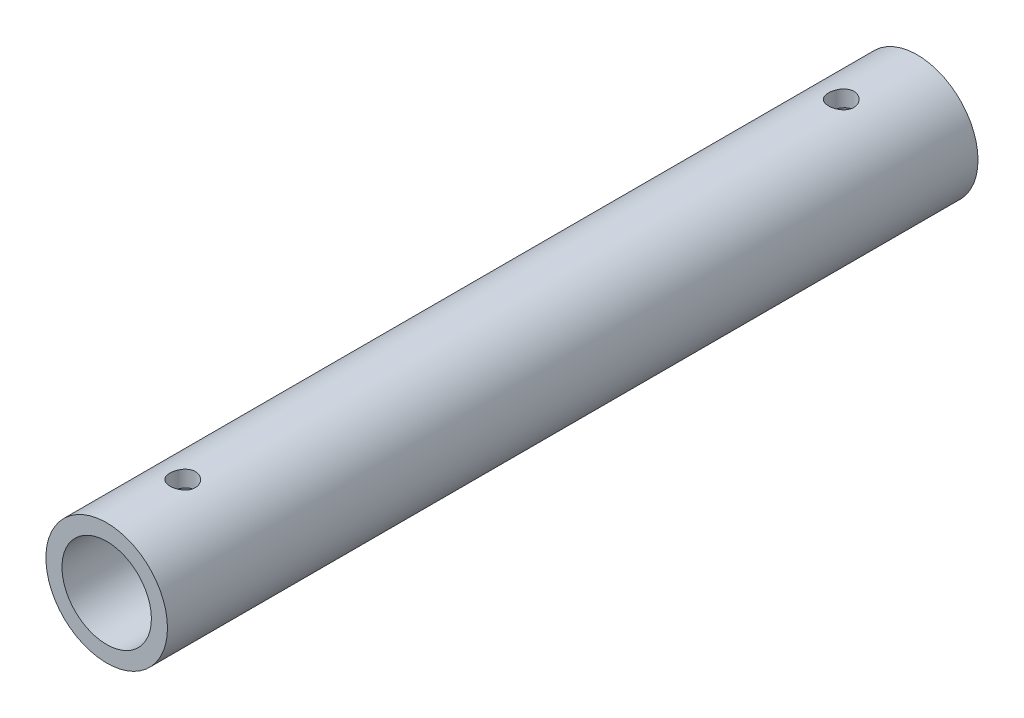
from build123d import *

# Parameters (mm, degrees)
SKETCH1_R               = 12
BOSS_EXTRUDE1_DEPTH     = 160
SHELL1_T                = -3.175
SKETCH2_R               = 2.5
CUT_EXTRUDE1_DEPTH      = 161.897482889
CUT_EXTRUDE1_DEPTH_BACK = 161.897482889


with BuildPart() as part:
    # Sketch1 → Boss-Extrude1 (new body)
    with BuildSketch(Plane.XY):
        Circle(SKETCH1_R)
    extrude(amount=BOSS_EXTRUDE1_DEPTH)

    # Shell1
    shell1_openings = [part.faces().sort_by_distance(p)[0] for p in [
        (0, 0, 160),
        (0, 0, 0),
    ]]
    offset(amount=SHELL1_T, openings=shell1_openings, kind=Kind.INTERSECTION)

    # Sketch2 → Cut-Extrude1 (cut, two sides)
    with BuildSketch(Plane(origin=(0, 0, 0), x_dir=(1, 0, 0), z_dir=(0, 1, 0))) as cut_extrude1_sk:
        with Locations(Location((0, -15, 0), (0, 0, 270))):
            Circle(SKETCH2_R)
        with Locations(Location((0, -145, 0), (0, 0, 270))):
            Circle(SKETCH2_R)
    extrude(amount=CUT_EXTRUDE1_DEPTH, mode=Mode.SUBTRACT)
    extrude(cut_extrude1_sk.sketch, amount=-CUT_EXTRUDE1_DEPTH_BACK, mode=Mode.SUBTRACT)


solid = part.part
